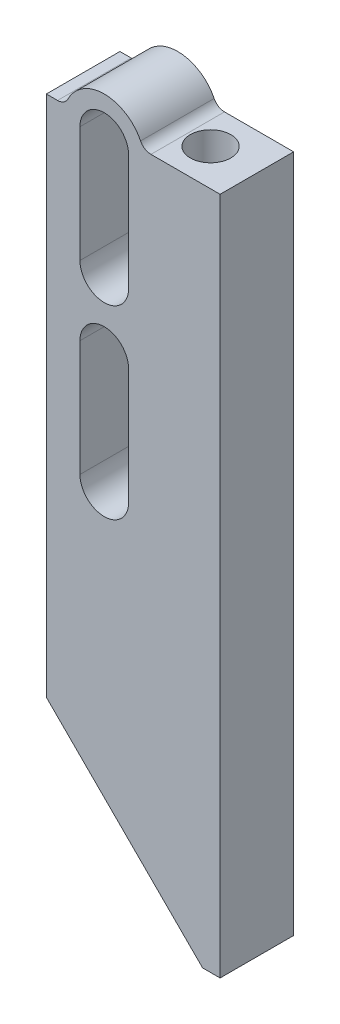
from build123d import *

# Parameters (mm, degrees)
BOSS_EXTRUDE1_DEPTH      = 3.175
BOSS_EXTRUDE1_DEPTH_BACK = 3.175
CUT_EXTRUDE1_DEPTH       = 7.35
SKETCH3_R                = 1.5
CUT_EXTRUDE2_DEPTH       = 25
SKETCH4_R                = 1.75
CUT_EXTRUDE3_DEPTH       = 5
FILLET1_R                = 1


with BuildPart() as part:
    # Sketch1 → Boss-Extrude1 (new body, two sides)
    with BuildSketch(Plane.XY) as boss_extrude1_sk:
        with BuildLine():
            Line((136.313708499, 40.4), (122.825, 53.888708499))
            Line((122.825, 53.888708499), (122.825, 99))
            Line((122.825, 99), (124.470898034, 99))
            ThreePointArc((124.470898034, 99), (127.825, 101.5), (131.179101966, 99))
            Line((131.179101966, 99), (137.825, 99))
            Line((137.825, 99), (137.825, 40.4))
            Line((137.825, 40.4), (136.313708499, 40.4))
        make_face()
    extrude(amount=BOSS_EXTRUDE1_DEPTH)
    extrude(boss_extrude1_sk.sketch, amount=-BOSS_EXTRUDE1_DEPTH_BACK)

    # Sketch2 → Cut-Extrude1 (cut, through all)
    with BuildSketch(Plane.XY.offset(3.175)):
        with BuildLine():
            Line((125.725, 72), (125.725, 82))
            ThreePointArc((125.725, 82), (127.825, 84.1), (129.925, 82))
            Line((129.925, 82), (129.925, 72))
            ThreePointArc((129.925, 72), (127.825, 69.9), (125.725, 72))
        make_face()
        with BuildLine():
            Line((125.725, 88), (125.725, 98))
            ThreePointArc((125.725, 98), (127.825, 100.1), (129.925, 98))
            Line((129.925, 98), (129.925, 88))
            ThreePointArc((129.925, 88), (127.825, 85.9), (125.725, 88))
        make_face()
    extrude(amount=-CUT_EXTRUDE1_DEPTH, mode=Mode.SUBTRACT)

    # Sketch3 → Cut-Extrude2 (cut)
    with BuildSketch(Plane(origin=(0, 99, 0), x_dir=(1, 0, 0), z_dir=(0, 1, 0))):
        with Locations((133.825, 0)):
            Circle(SKETCH3_R)
    extrude(amount=-CUT_EXTRUDE2_DEPTH, mode=Mode.SUBTRACT)

    # Sketch4 → Cut-Extrude3 (cut)
    with BuildSketch(Plane(origin=(0, 99, 0), x_dir=(-1, 0, 0), z_dir=(0, 1, 0))):
        with Locations((-133.825, 0)):
            Circle(SKETCH4_R)
    extrude(amount=-CUT_EXTRUDE3_DEPTH, mode=Mode.SUBTRACT)

    # Fillet1
    fillet1_edges = [part.edges().sort_by_distance(p)[0] for p in [
        (124.470898034, 99, 0),
        (131.179101966, 99, 0),
    ]]
    fillet(fillet1_edges, radius=FILLET1_R)


solid = part.part
